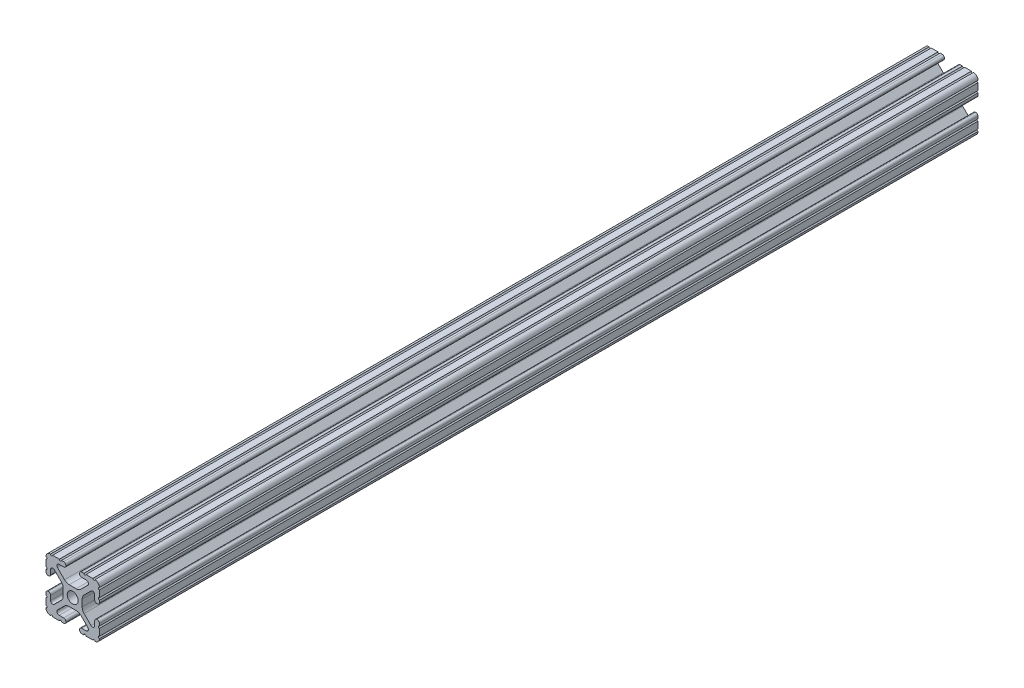
from build123d import *

# Parameters (mm, degrees)
SKETCH1_R               = 2.6035
BOSS_EXTRUDE1_DEPTH     = 304.8
SKETCH2_W               = 181.816409497
SKETCH2_H               = 28.139832977
SKETCH2_W_2             = 16.257599062
SKETCH2_H_2             = 27.586789262
CUT_EXTRUDE1_DEPTH      = 1.778
CUT_EXTRUDE1_DEPTH_BACK = 26.162


with BuildPart() as part:
    # Sketch1 → Boss-Extrude1 (new body, symmetric)
    with BuildSketch(Plane.XY):
        with BuildLine():
            Line((-7.179650497, -8.645192506), (-3.952270251, -5.423690499))
            ThreePointArc((-3.952270251, -5.423690499), (-2.922936451, -4.736929036), (-1.709253557, -4.4958))
            Line((-1.709253557, -4.4958), (1.709253557, -4.4958))
            ThreePointArc((1.709253557, -4.4958), (2.922936451, -4.736929036), (3.952270251, -5.423690499))
            Line((3.952270251, -5.423690499), (7.179650497, -8.645192506))
            ThreePointArc((7.179650497, -8.645192506), (7.41473083, -9.822813117), (6.416408329, -10.4902))
            Line((6.416408329, -10.4902), (4.287512407, -10.4902))
            ThreePointArc((4.287512407, -10.4902), (3.54574862, -10.79744862), (3.2385, -11.539212407))
            Line((3.2385, -11.539212407), (3.2385, -11.650987593))
            ThreePointArc((3.2385, -11.650987593), (3.54574862, -12.39275138), (4.287512407, -12.7))
            Line((4.287512407, -12.7), (5.317126718, -12.7))
            ThreePointArc((5.317126718, -12.7), (5.825126718, -12.192), (6.333126718, -12.7))
            Line((6.333126718, -12.7), (9.550443118, -12.7))
            ThreePointArc((9.550443118, -12.7), (10.058366869, -12.192000006), (10.566443095, -12.699847501))
            ThreePointArc((10.566443095, -12.699847501), (12.082537762, -12.08250727), (12.699846982, -10.566399977))
            ThreePointArc((12.699846982, -10.566399977), (12.192000006, -10.058323491), (12.7, -9.5504))
            Line((12.7, -9.5504), (12.7, -6.3330836))
            ThreePointArc((12.7, -6.3330836), (12.192, -5.8250836), (12.7, -5.3170836))
            Line((12.7, -5.3170836), (12.7, -4.287469289))
            ThreePointArc((12.7, -4.287469289), (12.39275138, -3.545705502), (11.650987593, -3.238456882))
            Line((11.650987593, -3.238456882), (11.539212407, -3.238456882))
            ThreePointArc((11.539212407, -3.238456882), (10.79744862, -3.545705502), (10.4902, -4.287469289))
            Line((10.4902, -4.287469289), (10.4902, -6.402089023))
            ThreePointArc((10.4902, -6.402089023), (9.856505071, -7.351067942), (8.737131347, -7.129408934))
            Line((8.737131347, -7.129408934), (5.441005833, -3.840816462))
            ThreePointArc((5.441005833, -3.840816462), (4.750877967, -2.809883091), (4.5085, -1.593185507))
            Line((4.5085, -1.593185507), (4.5085, 1.593185507))
            ThreePointArc((4.5085, 1.593185507), (4.750877967, 2.809883091), (5.441005833, 3.840816462))
            Line((5.441005833, 3.840816462), (8.737131347, 7.129408934))
            ThreePointArc((8.737131347, 7.129408934), (9.856505071, 7.351067942), (10.4902, 6.402089023))
            Line((10.4902, 6.402089023), (10.4902, 4.287469289))
            ThreePointArc((10.4902, 4.287469289), (10.79744862, 3.545705502), (11.539212407, 3.238456882))
            Line((11.539212407, 3.238456882), (11.650987593, 3.238456882))
            ThreePointArc((11.650987593, 3.238456882), (12.39275138, 3.545705502), (12.7, 4.287469289))
            Line((12.7, 4.287469289), (12.7, 5.3170836))
            ThreePointArc((12.7, 5.3170836), (12.192, 5.8250836), (12.7, 6.3330836))
            Line((12.7, 6.3330836), (12.7, 9.5504))
            ThreePointArc((12.7, 9.5504), (12.192000006, 10.058323491), (12.699846982, 10.566399977))
            ThreePointArc((12.699846982, 10.566399977), (12.082537762, 12.08250727), (10.566443095, 12.699847501))
            ThreePointArc((10.566443095, 12.699847501), (10.058366869, 12.192000006), (9.550443118, 12.7))
            Line((9.550443118, 12.7), (6.333126718, 12.7))
            ThreePointArc((6.333126718, 12.7), (5.825126718, 12.192), (5.317126718, 12.7))
            Line((5.317126718, 12.7), (4.287512407, 12.7))
            ThreePointArc((4.287512407, 12.7), (3.54574862, 12.39275138), (3.2385, 11.650987593))
            Line((3.2385, 11.650987593), (3.2385, 11.539212407))
            ThreePointArc((3.2385, 11.539212407), (3.54574862, 10.79744862), (4.287512407, 10.4902))
            Line((4.287512407, 10.4902), (6.476788598, 10.4902))
            ThreePointArc((6.476788598, 10.4902), (7.432222385, 9.85140422), (7.207036008, 8.724370562))
            Line((7.207036008, 8.724370562), (3.898272566, 5.423169045))
            ThreePointArc((3.898272566, 5.423169045), (2.869120213, 4.736787962), (1.655778399, 4.4958))
            Line((1.655778399, 4.4958), (-1.655778399, 4.4958))
            ThreePointArc((-1.655778399, 4.4958), (-2.869120213, 4.736787962), (-3.898272566, 5.423169045))
            Line((-3.898272566, 5.423169045), (-7.207036008, 8.724370562))
            ThreePointArc((-7.207036008, 8.724370562), (-7.432222385, 9.85140422), (-6.476788598, 10.4902))
            Line((-6.476788598, 10.4902), (-4.287512407, 10.4902))
            ThreePointArc((-4.287512407, 10.4902), (-3.54574862, 10.79744862), (-3.2385, 11.539212407))
            Line((-3.2385, 11.539212407), (-3.2385, 11.650987593))
            ThreePointArc((-3.2385, 11.650987593), (-3.54574862, 12.39275138), (-4.287512407, 12.7))
            Line((-4.287512407, 12.7), (-5.317126718, 12.7))
            ThreePointArc((-5.317126718, 12.7), (-5.825126718, 12.192), (-6.333126718, 12.7))
            Line((-6.333126718, 12.7), (-9.550443118, 12.7))
            ThreePointArc((-9.550443118, 12.7), (-10.058366869, 12.192000006), (-10.566443095, 12.699847501))
            ThreePointArc((-10.566443095, 12.699847501), (-12.082537762, 12.08250727), (-12.699846982, 10.566399977))
            ThreePointArc((-12.699846982, 10.566399977), (-12.192000006, 10.058323491), (-12.7, 9.5504))
            Line((-12.7, 9.5504), (-12.7, 6.3330836))
            ThreePointArc((-12.7, 6.3330836), (-12.192, 5.8250836), (-12.7, 5.3170836))
            Line((-12.7, 5.3170836), (-12.7, 4.287469289))
            ThreePointArc((-12.7, 4.287469289), (-12.39275138, 3.545705502), (-11.650987593, 3.238456882))
            Line((-11.650987593, 3.238456882), (-11.539212407, 3.238456882))
            ThreePointArc((-11.539212407, 3.238456882), (-10.79744862, 3.545705502), (-10.4902, 4.287469289))
            Line((-10.4902, 4.287469289), (-10.4902, 6.402089023))
            ThreePointArc((-10.4902, 6.402089023), (-9.856505071, 7.351067942), (-8.737131347, 7.129408934))
            Line((-8.737131347, 7.129408934), (-5.441005833, 3.840816462))
            ThreePointArc((-5.441005833, 3.840816462), (-4.750877967, 2.809883091), (-4.5085, 1.593185507))
            Line((-4.5085, 1.593185507), (-4.5085, -1.593185507))
            ThreePointArc((-4.5085, -1.593185507), (-4.750877967, -2.809883091), (-5.441005833, -3.840816462))
            Line((-5.441005833, -3.840816462), (-8.737131347, -7.129408934))
            ThreePointArc((-8.737131347, -7.129408934), (-9.856505071, -7.351067942), (-10.4902, -6.402089023))
            Line((-10.4902, -6.402089023), (-10.4902, -4.287469289))
            ThreePointArc((-10.4902, -4.287469289), (-10.79744862, -3.545705502), (-11.539212407, -3.238456882))
            Line((-11.539212407, -3.238456882), (-11.650987593, -3.238456882))
            ThreePointArc((-11.650987593, -3.238456882), (-12.39275138, -3.545705502), (-12.7, -4.287469289))
            Line((-12.7, -4.287469289), (-12.7, -5.3170836))
            ThreePointArc((-12.7, -5.3170836), (-12.192, -5.8250836), (-12.7, -6.3330836))
            Line((-12.7, -6.3330836), (-12.7, -9.5504))
            ThreePointArc((-12.7, -9.5504), (-12.192000006, -10.058323491), (-12.699846982, -10.566399977))
            ThreePointArc((-12.699846982, -10.566399977), (-12.082537762, -12.08250727), (-10.566443095, -12.699847501))
            ThreePointArc((-10.566443095, -12.699847501), (-10.058366869, -12.192000006), (-9.550443118, -12.7))
            Line((-9.550443118, -12.7), (-6.333126718, -12.7))
            ThreePointArc((-6.333126718, -12.7), (-5.825126718, -12.192), (-5.317126718, -12.7))
            Line((-5.317126718, -12.7), (-4.287512407, -12.7))
            ThreePointArc((-4.287512407, -12.7), (-3.54574862, -12.39275138), (-3.2385, -11.650987593))
            Line((-3.2385, -11.650987593), (-3.2385, -11.539212407))
            ThreePointArc((-3.2385, -11.539212407), (-3.54574862, -10.79744862), (-4.287512407, -10.4902))
            Line((-4.287512407, -10.4902), (-6.416408329, -10.4902))
            ThreePointArc((-6.416408329, -10.4902), (-7.41473083, -9.822813117), (-7.179650497, -8.645192506))
        make_face()
        Circle(SKETCH1_R, mode=Mode.SUBTRACT)
    extrude(amount=BOSS_EXTRUDE1_DEPTH, both=True)

    # Sketch2 → Cut-Extrude1 (cut, two sides)
    with BuildSketch(Plane(origin=(12.7, 0, 0), x_dir=(0, 0, -1), z_dir=(1, 0, 0))) as cut_extrude1_sk:
        with Locations((219.834861418, -0.164612138)):
            Rectangle(SKETCH2_W, SKETCH2_H)
        with Locations((-297.347005301, -0.441133996)):
            Rectangle(SKETCH2_W_2, SKETCH2_H_2)
    extrude(amount=CUT_EXTRUDE1_DEPTH, mode=Mode.SUBTRACT)
    extrude(cut_extrude1_sk.sketch, amount=-CUT_EXTRUDE1_DEPTH_BACK, mode=Mode.SUBTRACT)


solid = part.part
